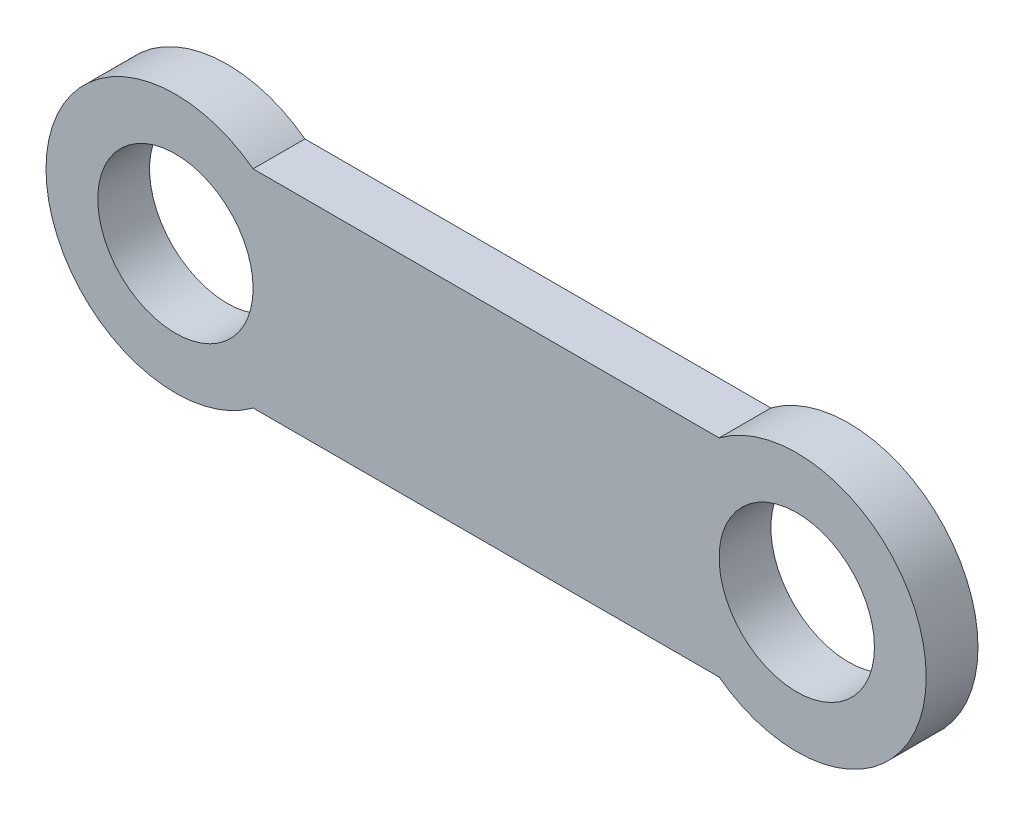
from build123d import *

# Parameters (mm, degrees)
SKETCH_1_R      = 1.5
EXTRUDE_1_DEPTH = 1


with BuildPart() as part:
    # 草图1 → 凸台-拉伸1 (new body)
    with BuildSketch(Plane.XY):
        with BuildLine():
            Line((-4.5, 2), (4.5, 2))
            ThreePointArc((4.5, 2), (8.5, 0), (4.5, -2))
            Line((4.5, -2), (-4.5, -2))
            ThreePointArc((-4.5, -2), (-8.5, 0), (-4.5, 2))
        make_face()
        with Locations((6, 0)):
            Circle(SKETCH_1_R, mode=Mode.SUBTRACT)
        with Locations((-6, 0)):
            Circle(SKETCH_1_R, mode=Mode.SUBTRACT)
    extrude(amount=EXTRUDE_1_DEPTH)


solid = part.part
